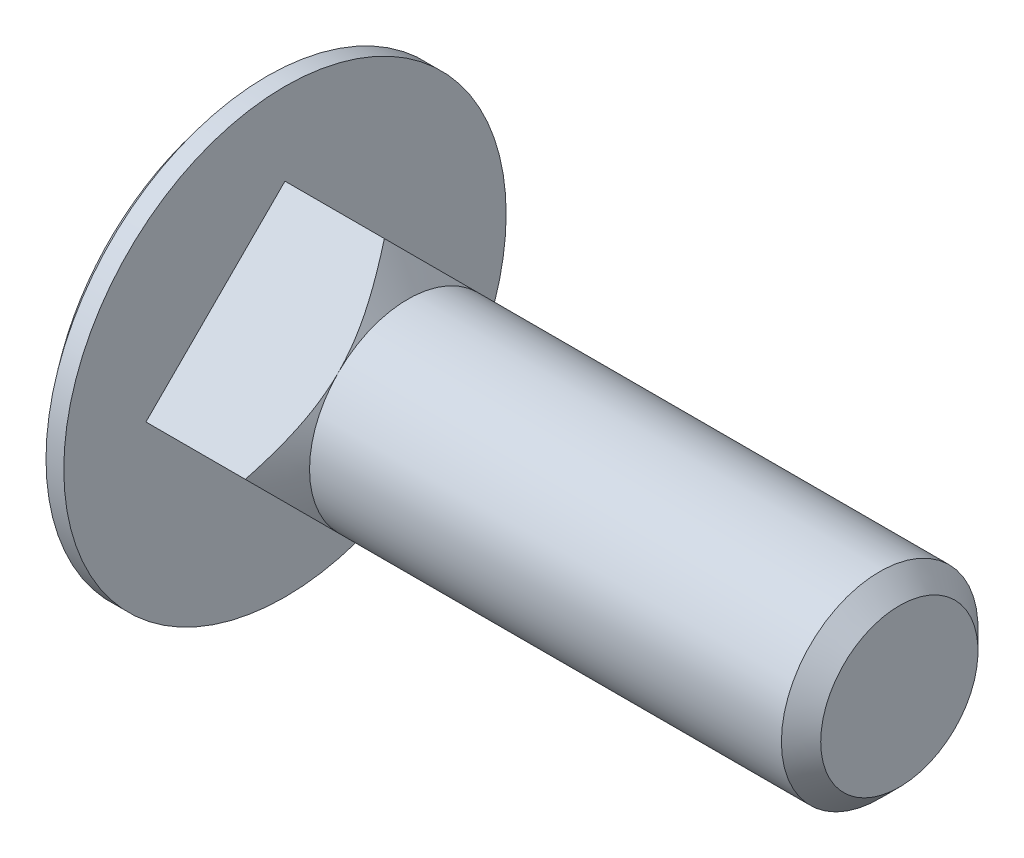
from build123d import *

# Parameters (mm, degrees)
EXTRUDE_1_DEPTH = 5
CHAMFER_1_SIZE  = 0.8


with BuildPart() as part:
    # Эскиз1 → Повернуть1 (revolve)
    with BuildSketch(Plane.XY, mode=Mode.PRIVATE) as revolve_1_sk:
        with BuildLine():
            Line((-0.723805295, 9), (0, 9))
            Line((0, 9), (0, 4))
            Line((0, 4), (25, 4))
            Line((25, 4), (25, 0))
            Line((25, 0), (-4, 0))
            ThreePointArc((-4, 0), (-3.155479355, 4.78887909), (-0.723805295, 9))
        make_face()
    revolve(revolve_1_sk.sketch.rotate(Axis((-168.009043504, 0, 0), (1, 0, 0)), 90), axis=Axis((-168.009043504, 0, 0), (1, 0, 0)))

    # Эскиз2 → Бобышка-Вытянуть1 (add)
    with BuildSketch(Plane(origin=(0, 0, 0), x_dir=(0, 0, -1), z_dir=(1, 0, 0))):
        Polygon((0, 5.656854249), (-5.656854249, 0), (0, -5.656854249), (5.656854249, 0), align=None)
    extrude(amount=EXTRUDE_1_DEPTH)

    # Эскиз3 → Вырез-Повернуть1 (revolve, cut)
    with BuildSketch(Plane.XY):
        Polygon((5, 4), (4.043414753, 5.656854249), (5, 5.656854249), align=None)
    revolve(axis=Axis((-1000, 0, 0), (1, 0, 0)), mode=Mode.SUBTRACT)

    # Фаска1
    chamfer_1_edges = [part.edges().sort_by_distance(p)[0] for p in [
        (25, 0, -4),
    ]]
    chamfer(chamfer_1_edges, length=CHAMFER_1_SIZE)


solid = part.part
